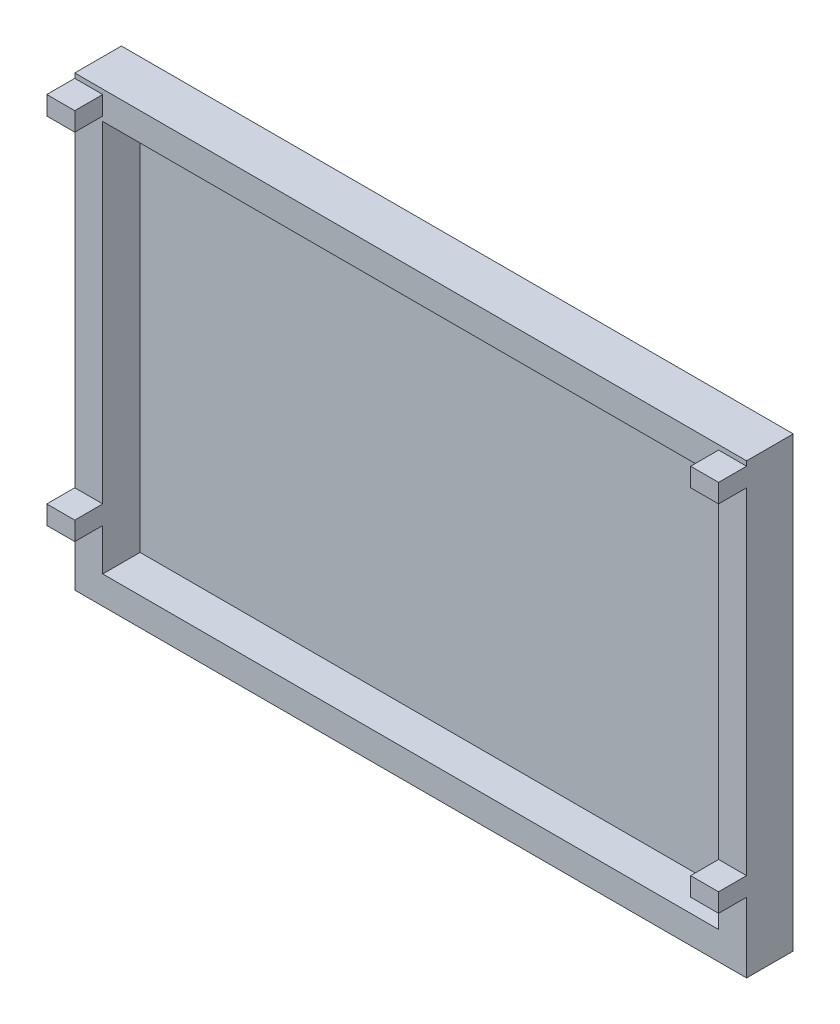
from build123d import *

# Parameters (mm, degrees)
SKETCH1_W           = 1828.8
SKETCH1_H           = 1219.2
BOSS_EXTRUDE1_DEPTH = 127
SKETCH2_W           = 1676.4
SKETCH2_H           = 1066.8
CUT_EXTRUDE2_DEPTH  = 101.6
SKETCH3_W           = 76.2
SKETCH3_H           = 50.8
BOSS_EXTRUDE2_DEPTH = 76.2
SKETCH4_W           = 76.2
SKETCH4_H           = 50.8
BOSS_EXTRUDE3_DEPTH = 76.2
SKETCH5_W           = 76.2
SKETCH5_H           = 50.8
BOSS_EXTRUDE4_DEPTH = 76.2


with BuildPart() as part:
    # Sketch1 → Boss-Extrude1 (new body)
    with BuildSketch(Plane.XY):
        with Locations((914.4, 609.6)):
            Rectangle(SKETCH1_W, SKETCH1_H)
    extrude(amount=BOSS_EXTRUDE1_DEPTH)

    # Sketch2 → Cut-Extrude2 (cut)
    with BuildSketch(Plane.XY.offset(127)):
        with Locations((914.4, 609.6)):
            Rectangle(SKETCH2_W, SKETCH2_H)
    extrude(amount=-CUT_EXTRUDE2_DEPTH, mode=Mode.SUBTRACT)

    # Sketch3 → Boss-Extrude2 (add)
    with BuildSketch(Plane.XY.offset(127)):
        with Locations((38.1, 1181.1)):
            Rectangle(SKETCH3_W, SKETCH3_H)
    extrude(amount=BOSS_EXTRUDE2_DEPTH)

    # Sketch4 → Boss-Extrude3 (add)
    with BuildSketch(Plane.XY.offset(127)):
        with Locations((1790.7, 1181.1)):
            Rectangle(SKETCH4_W, SKETCH4_H)
    extrude(amount=BOSS_EXTRUDE3_DEPTH)

    # Sketch5 → Boss-Extrude4 (add)
    with BuildSketch(Plane.XY.offset(127)):
        with Locations((38.1, 215.9)):
            Rectangle(SKETCH5_W, SKETCH5_H)
        with Locations((1790.7, 215.9)):
            Rectangle(SKETCH5_W, SKETCH5_H)
    extrude(amount=BOSS_EXTRUDE4_DEPTH)


solid = part.part
